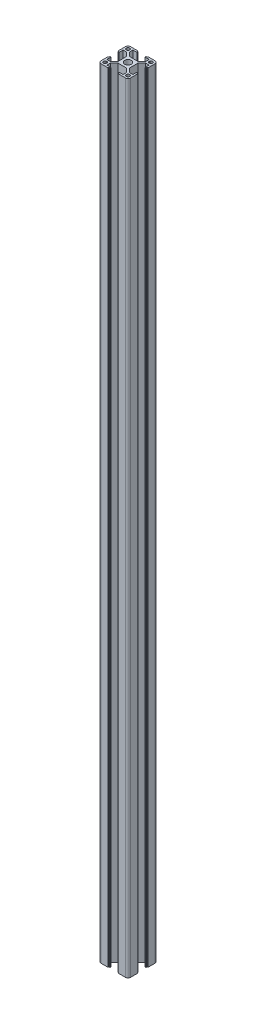
from build123d import *

# Parameters (mm, degrees)
SKETCH_3_R          = 3.4
EXTRUDE_1_DEPTH     = 789
SKETCH_4_R          = 3
CUT_EXTRUDE_1_DEPTH = 86


with BuildPart() as part:
    # 草图3 → 凸台-拉伸1 (new body)
    with BuildSketch(Plane(origin=(0, 0, 0), x_dir=(1, 0, 0), z_dir=(0, 1, 0))):
        with BuildLine():
            Line((-15, -12.5), (-15, -5.4))
            ThreePointArc((-15, -5.4), (-14.941421356, -5.258578644), (-14.8, -5.2))
            Line((-14.8, -5.2), (-14.4, -5.2))
            ThreePointArc((-14.4, -5.2), (-14.258578644, -5.141421356), (-14.2, -5))
            Line((-14.2, -5), (-14.2, -4.3))
            ThreePointArc((-14.2, -4.3), (-14.141421356, -4.158578644), (-14, -4.1))
            Line((-14, -4.1), (-13.2, -4.1))
            Line((-13.2, -4.1), (-13.2, -8.25))
            Line((-13.2, -8.25), (-9.522792206, -8.25))
            Line((-9.522792206, -8.25), (-5.8, -4.527207794))
            Line((-5.8, -4.527207794), (-5.8, 4.527207794))
            Line((-5.8, 4.527207794), (-9.522792206, 8.25))
            Line((-9.522792206, 8.25), (-13.2, 8.25))
            Line((-13.2, 8.25), (-13.2, 4.1))
            Line((-13.2, 4.1), (-14, 4.1))
            ThreePointArc((-14, 4.1), (-14.141421356, 4.158578644), (-14.2, 4.3))
            Line((-14.2, 4.3), (-14.2, 5))
            ThreePointArc((-14.2, 5), (-14.258578644, 5.141421356), (-14.4, 5.2))
            Line((-14.4, 5.2), (-14.8, 5.2))
            ThreePointArc((-14.8, 5.2), (-14.941421356, 5.258578644), (-15, 5.4))
            Line((-15, 5.4), (-15, 12.5))
            ThreePointArc((-15, 12.5), (-14.267766953, 14.267766953), (-12.5, 15))
            Line((-12.5, 15), (-5.4, 15))
            ThreePointArc((-5.4, 15), (-5.258578644, 14.941421356), (-5.2, 14.8))
            Line((-5.2, 14.8), (-5.2, 14.4))
            ThreePointArc((-5.2, 14.4), (-5.141421356, 14.258578644), (-5, 14.2))
            Line((-5, 14.2), (-4.3, 14.2))
            ThreePointArc((-4.3, 14.2), (-4.158578644, 14.141421356), (-4.1, 14))
            Line((-4.1, 14), (-4.1, 13.2))
            Line((-4.1, 13.2), (-8.25, 13.2))
            Line((-8.25, 13.2), (-8.25, 9.522792206))
            Line((-8.25, 9.522792206), (-4.527207794, 5.8))
            Line((-4.527207794, 5.8), (4.527207794, 5.8))
            Line((4.527207794, 5.8), (8.25, 9.522792206))
            Line((8.25, 9.522792206), (8.25, 13.2))
            Line((8.25, 13.2), (4.1, 13.2))
            Line((4.1, 13.2), (4.1, 14))
            ThreePointArc((4.1, 14), (4.158578644, 14.141421356), (4.3, 14.2))
            Line((4.3, 14.2), (5, 14.2))
            ThreePointArc((5, 14.2), (5.141421356, 14.258578644), (5.2, 14.4))
            Line((5.2, 14.4), (5.2, 14.8))
            ThreePointArc((5.2, 14.8), (5.258578644, 14.941421356), (5.4, 15))
            Line((5.4, 15), (12.5, 15))
            ThreePointArc((12.5, 15), (14.267766953, 14.267766953), (15, 12.5))
            Line((15, 12.5), (15, 5.4))
            ThreePointArc((15, 5.4), (14.941421356, 5.258578644), (14.8, 5.2))
            Line((14.8, 5.2), (14.4, 5.2))
            ThreePointArc((14.4, 5.2), (14.258578644, 5.141421356), (14.2, 5))
            Line((14.2, 5), (14.2, 4.3))
            ThreePointArc((14.2, 4.3), (14.141421356, 4.158578644), (14, 4.1))
            Line((14, 4.1), (13.2, 4.1))
            Line((13.2, 4.1), (13.2, 8.25))
            Line((13.2, 8.25), (9.522792206, 8.25))
            Line((9.522792206, 8.25), (5.8, 4.527207794))
            Line((5.8, 4.527207794), (5.8, -4.527207794))
            Line((5.8, -4.527207794), (9.522792206, -8.25))
            Line((9.522792206, -8.25), (13.2, -8.25))
            Line((13.2, -8.25), (13.2, -4.1))
            Line((13.2, -4.1), (14, -4.1))
            ThreePointArc((14, -4.1), (14.141421356, -4.158578644), (14.2, -4.3))
            Line((14.2, -4.3), (14.2, -5))
            ThreePointArc((14.2, -5), (14.258578644, -5.141421356), (14.4, -5.2))
            Line((14.4, -5.2), (14.8, -5.2))
            ThreePointArc((14.8, -5.2), (14.941421356, -5.258578644), (15, -5.4))
            Line((15, -5.4), (15, -12.5))
            ThreePointArc((15, -12.5), (14.267766953, -14.267766953), (12.5, -15))
            Line((12.5, -15), (5.4, -15))
            ThreePointArc((5.4, -15), (5.258578644, -14.941421356), (5.2, -14.8))
            Line((5.2, -14.8), (5.2, -14.4))
            ThreePointArc((5.2, -14.4), (5.141421356, -14.258578644), (5, -14.2))
            Line((5, -14.2), (4.3, -14.2))
            ThreePointArc((4.3, -14.2), (4.158578644, -14.141421356), (4.1, -14))
            Line((4.1, -14), (4.1, -13.2))
            Line((4.1, -13.2), (8.25, -13.2))
            Line((8.25, -13.2), (8.25, -9.522792206))
            Line((8.25, -9.522792206), (4.527207794, -5.8))
            Line((4.527207794, -5.8), (-4.527207794, -5.8))
            Line((-4.527207794, -5.8), (-8.25, -9.522792206))
            Line((-8.25, -9.522792206), (-8.25, -13.2))
            Line((-8.25, -13.2), (-4.1, -13.2))
            Line((-4.1, -13.2), (-4.1, -14))
            ThreePointArc((-4.1, -14), (-4.158578644, -14.141421356), (-4.3, -14.2))
            Line((-4.3, -14.2), (-5, -14.2))
            ThreePointArc((-5, -14.2), (-5.141421356, -14.258578644), (-5.2, -14.4))
            Line((-5.2, -14.4), (-5.2, -14.8))
            ThreePointArc((-5.2, -14.8), (-5.258578644, -14.941421356), (-5.4, -15))
            Line((-5.4, -15), (-12.5, -15))
            ThreePointArc((-12.5, -15), (-14.267766953, -14.267766953), (-15, -12.5))
        make_face()
        Circle(SKETCH_3_R, mode=Mode.SUBTRACT)
        with BuildLine():
            Line((-13.2, -12.2), (-13.2, -11.05))
            ThreePointArc((-13.2, -11.05), (-12.907106781, -10.342893219), (-12.2, -10.05))
            Line((-12.2, -10.05), (-11.05, -10.05))
            ThreePointArc((-11.05, -10.05), (-10.342893219, -10.342893219), (-10.05, -11.05))
            Line((-10.05, -11.05), (-10.05, -12.2))
            ThreePointArc((-10.05, -12.2), (-10.342893219, -12.907106781), (-11.05, -13.2))
            Line((-11.05, -13.2), (-12.2, -13.2))
            ThreePointArc((-12.2, -13.2), (-12.907106781, -12.907106781), (-13.2, -12.2))
        make_face(mode=Mode.SUBTRACT)
        with BuildLine():
            Line((-10.05, 12.2), (-10.05, 11.05))
            ThreePointArc((-10.05, 11.05), (-10.342893219, 10.342893219), (-11.05, 10.05))
            Line((-11.05, 10.05), (-12.2, 10.05))
            ThreePointArc((-12.2, 10.05), (-12.907106781, 10.342893219), (-13.2, 11.05))
            Line((-13.2, 11.05), (-13.2, 12.2))
            ThreePointArc((-13.2, 12.2), (-12.907106781, 12.907106781), (-12.2, 13.2))
            Line((-12.2, 13.2), (-11.05, 13.2))
            ThreePointArc((-11.05, 13.2), (-10.342893219, 12.907106781), (-10.05, 12.2))
        make_face(mode=Mode.SUBTRACT)
        with BuildLine():
            Line((13.2, 12.2), (13.2, 11.05))
            ThreePointArc((13.2, 11.05), (12.907106781, 10.342893219), (12.2, 10.05))
            Line((12.2, 10.05), (11.05, 10.05))
            ThreePointArc((11.05, 10.05), (10.342893219, 10.342893219), (10.05, 11.05))
            Line((10.05, 11.05), (10.05, 12.2))
            ThreePointArc((10.05, 12.2), (10.342893219, 12.907106781), (11.05, 13.2))
            Line((11.05, 13.2), (12.2, 13.2))
            ThreePointArc((12.2, 13.2), (12.907106781, 12.907106781), (13.2, 12.2))
        make_face(mode=Mode.SUBTRACT)
        with BuildLine():
            Line((10.05, -12.2), (10.05, -11.05))
            ThreePointArc((10.05, -11.05), (10.342893219, -10.342893219), (11.05, -10.05))
            Line((11.05, -10.05), (12.2, -10.05))
            ThreePointArc((12.2, -10.05), (12.907106781, -10.342893219), (13.2, -11.05))
            Line((13.2, -11.05), (13.2, -12.2))
            ThreePointArc((13.2, -12.2), (12.907106781, -12.907106781), (12.2, -13.2))
            Line((12.2, -13.2), (11.05, -13.2))
            ThreePointArc((11.05, -13.2), (10.342893219, -12.907106781), (10.05, -12.2))
        make_face(mode=Mode.SUBTRACT)
    extrude(amount=EXTRUDE_1_DEPTH)

    # 草图4 → 切除-拉伸1 (cut)
    with BuildSketch(Plane.XY.offset(5.8)):
        with Locations((0, 609)):
            Circle(SKETCH_4_R)
        with Locations((0, 180)):
            Circle(SKETCH_4_R)
    extrude(amount=-CUT_EXTRUDE_1_DEPTH, mode=Mode.SUBTRACT)


solid = part.part
